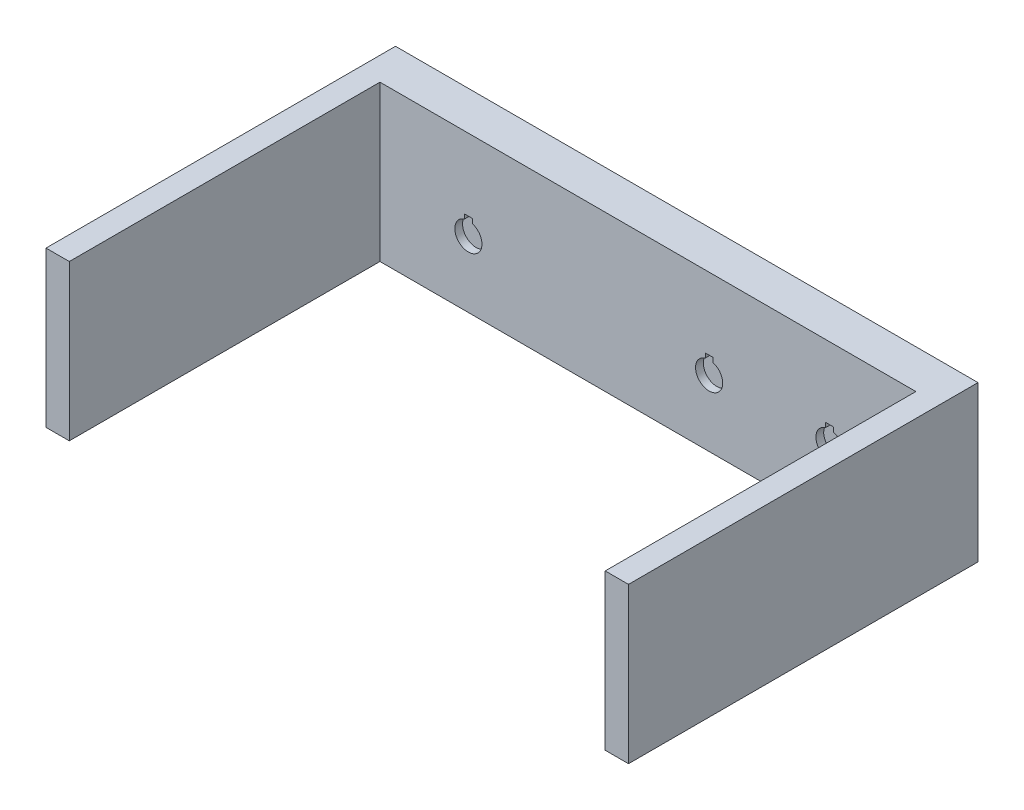
from build123d import *

# Parameters (mm, degrees)
SKETCH1_W           = 150
SKETCH1_H           = 40
BOSS_EXTRUDE1_DEPTH = 10
SKETCH2_W           = 130
SKETCH2_H           = 6
CUT_EXTRUDE1_DEPTH  = 34
CUT_EXTRUDE3_DEPTH  = 10
BOSS_EXTRUDE2_DEPTH = 2
SKETCH5_W           = 6
SKETCH5_H           = 40
BOSS_EXTRUDE3_DEPTH = 80


with BuildPart() as part:
    # Sketch1 → Boss-Extrude1 (new body)
    with BuildSketch(Plane.XY):
        Rectangle(SKETCH1_W, SKETCH1_H)
    extrude(amount=BOSS_EXTRUDE1_DEPTH)

    # Sketch2 → Cut-Extrude1 (cut)
    with BuildSketch(Plane.XZ.offset(20)):
        with Locations((0.265824487, 5)):
            Rectangle(SKETCH2_W, SKETCH2_H)
    extrude(amount=-CUT_EXTRUDE1_DEPTH, mode=Mode.SUBTRACT)

    # Sketch3 → Cut-Extrude3 (cut)
    with BuildSketch(Plane.XY.offset(10)):
        with BuildLine():
            Line((16.765824487, 1.504101966), (16.765824487, 0.354101966))
            ThreePointArc((16.765824487, 0.354101966), (15.765824487, -6.5), (14.765824487, 0.354101966))
            Line((14.765824487, 0.354101966), (14.765824487, 1.504101966))
            Line((14.765824487, 1.504101966), (16.765824487, 1.504101966))
        make_face()
        with BuildLine():
            Line((-45.234175513, 1.504101966), (-47.234175513, 1.504101966))
            Line((-47.234175513, 1.504101966), (-47.234175513, 0.354101966))
            ThreePointArc((-47.234175513, 0.354101966), (-46.234175513, -6.5), (-45.234175513, 0.354101966))
            Line((-45.234175513, 0.354101966), (-45.234175513, 1.504101966))
        make_face()
        with BuildLine():
            Line((47.765824487, 1.504101966), (47.765824487, 0.354101966))
            ThreePointArc((47.765824487, 0.354101966), (46.765824487, -6.5), (45.765824487, 0.354101966))
            Line((45.765824487, 0.354101966), (45.765824487, 1.504101966))
            Line((45.765824487, 1.504101966), (47.765824487, 1.504101966))
        make_face()
    extrude(amount=-CUT_EXTRUDE3_DEPTH, mode=Mode.SUBTRACT)

    # Sketch4 → Boss-Extrude2 (add)
    with BuildSketch(Plane(origin=(0, 0, 0), x_dir=(-1, 0, 0), z_dir=(0, 0, -1))):
        with BuildLine():
            Line((-47.765824487, 0.354101966), (-47.765824487, 1.504101966))
            Line((-47.765824487, 1.504101966), (-45.765824487, 1.504101966))
            Line((-45.765824487, 1.504101966), (-45.765824487, 0.354101966))
            ThreePointArc((-45.765824487, 0.354101966), (-46.765824487, 0.5), (-47.765824487, 0.354101966))
        make_face()
        with BuildLine():
            Line((-14.765824487, 1.504101966), (-14.765824487, 0.354101966))
            ThreePointArc((-14.765824487, 0.354101966), (-15.765824487, 0.5), (-16.765824487, 0.354101966))
            Line((-16.765824487, 0.354101966), (-16.765824487, 1.504101966))
            Line((-16.765824487, 1.504101966), (-14.765824487, 1.504101966))
        make_face()
        with BuildLine():
            Line((47.234175513, 1.504101966), (47.234175513, 0.354101966))
            ThreePointArc((47.234175513, 0.354101966), (46.234175513, 0.5), (45.234175513, 0.354101966))
            Line((45.234175513, 0.354101966), (45.234175513, 1.504101966))
            Line((45.234175513, 1.504101966), (47.234175513, 1.504101966))
        make_face()
    extrude(amount=-BOSS_EXTRUDE2_DEPTH)

    # Sketch5 → Boss-Extrude3 (add)
    with BuildSketch(Plane.XY.offset(10)):
        with Locations((-72, 0)):
            Rectangle(SKETCH5_W, SKETCH5_H)
        with Locations((72, 0)):
            Rectangle(SKETCH5_W, SKETCH5_H)
    extrude(amount=BOSS_EXTRUDE3_DEPTH)


solid = part.part
